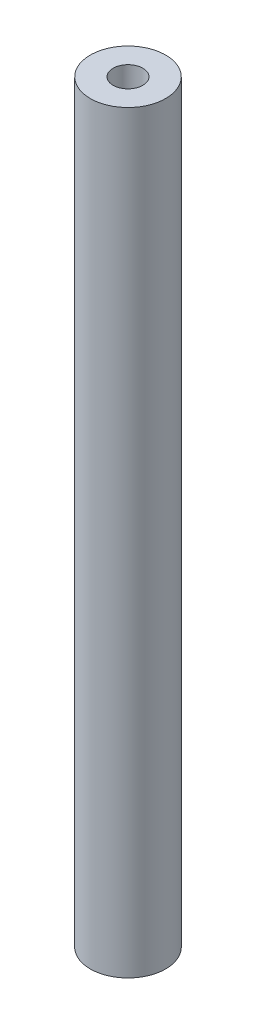
from build123d import *

# Parameters (mm, degrees)
SKETCH1_R                 = 3.175
BOSS_EXTRUDE1_DEPTH       = 63.5
M3X0_5_TAPPED_HOLE1_D     = 2.5
M3X0_5_TAPPED_HOLE1_DEPTH = 12.7
M3X0_5_TAPPED_HOLE1_TIP   = 0.751075774
M3X0_5_TAPPED_HOLE2_D     = 2.5
M3X0_5_TAPPED_HOLE2_DEPTH = 12.7
M3X0_5_TAPPED_HOLE2_TIP   = 0.751075774


with BuildPart() as part:
    # Sketch1 → Boss-Extrude1 (new body)
    with BuildSketch(Plane(origin=(0, 0, 0), x_dir=(1, 0, 0), z_dir=(0, 1, 0))):
        Circle(SKETCH1_R)
    extrude(amount=BOSS_EXTRUDE1_DEPTH)

    # M3x0.5 Tapped Hole1
    with Locations(Plane(origin=(0, 63.5, 0), x_dir=(1, 0, 0), z_dir=(0, 1, 0))):
        with Locations((0, 0)):
            Hole(M3X0_5_TAPPED_HOLE1_D / 2, depth=M3X0_5_TAPPED_HOLE1_DEPTH)
            with Locations((0, 0, -(M3X0_5_TAPPED_HOLE1_DEPTH + M3X0_5_TAPPED_HOLE1_TIP / 2))):  # 118° drill point
                Cone(0, M3X0_5_TAPPED_HOLE1_D / 2, M3X0_5_TAPPED_HOLE1_TIP, mode=Mode.SUBTRACT)

    # M3x0.5 Tapped Hole2
    with Locations(Plane(origin=(0, 0, 0), x_dir=(-1, 0, 0), z_dir=(0, -1, 0))):
        with Locations((0, 0)):
            Hole(M3X0_5_TAPPED_HOLE2_D / 2, depth=M3X0_5_TAPPED_HOLE2_DEPTH)
            with Locations((0, 0, -(M3X0_5_TAPPED_HOLE2_DEPTH + M3X0_5_TAPPED_HOLE2_TIP / 2))):  # 118° drill point
                Cone(0, M3X0_5_TAPPED_HOLE2_D / 2, M3X0_5_TAPPED_HOLE2_TIP, mode=Mode.SUBTRACT)


solid = part.part
